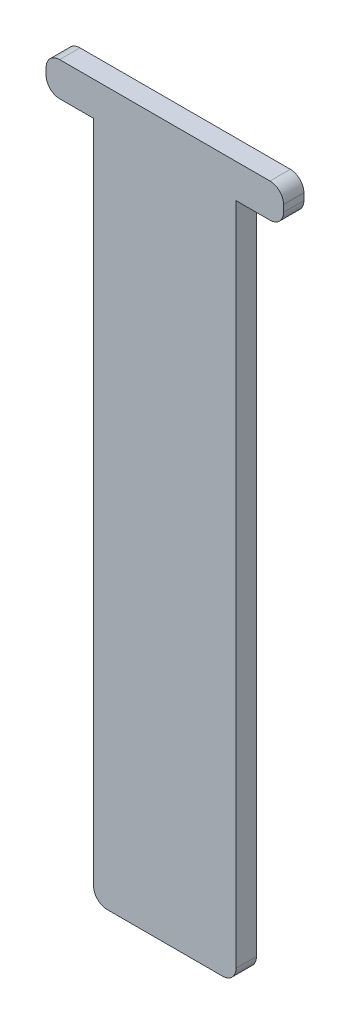
from build123d import *

# Parameters (mm, degrees)
BOSS_EXTRUDE1_DEPTH = 3


with BuildPart() as part:
    # Sketch1 → Boss-Extrude1 (new body)
    with BuildSketch(Plane.XY):
        with BuildLine():
            Line((-16.760970728, 91.057377049), (14.239029272, 91.057377049))
            ThreePointArc((14.239029272, 91.057377049), (15.653242834, 90.471590612), (16.239029272, 89.057377049))
            Line((16.239029272, 89.057377049), (16.239029272, 88.057377049))
            ThreePointArc((16.239029272, 88.057377049), (15.653242834, 86.643163487), (14.239029272, 86.057377049))
            Line((14.239029272, 86.057377049), (9.239029272, 86.057377049))
            Line((9.239029272, 86.057377049), (9.239029272, -11.942622951))
            ThreePointArc((9.239029272, -11.942622951), (8.653242834, -13.356836513), (7.239029272, -13.942622951))
            Line((7.239029272, -13.942622951), (-9.760970728, -13.942622951))
            ThreePointArc((-9.760970728, -13.942622951), (-11.175184291, -13.356836513), (-11.760970728, -11.942622951))
            Line((-11.760970728, -11.942622951), (-11.760970728, 86.057377049))
            Line((-11.760970728, 86.057377049), (-16.760970728, 86.057377049))
            ThreePointArc((-16.760970728, 86.057377049), (-18.175184291, 86.643163487), (-18.760970728, 88.057377049))
            Line((-18.760970728, 88.057377049), (-18.760970728, 89.057377049))
            ThreePointArc((-18.760970728, 89.057377049), (-18.175184291, 90.471590612), (-16.760970728, 91.057377049))
        make_face()
    extrude(amount=BOSS_EXTRUDE1_DEPTH)


solid = part.part
